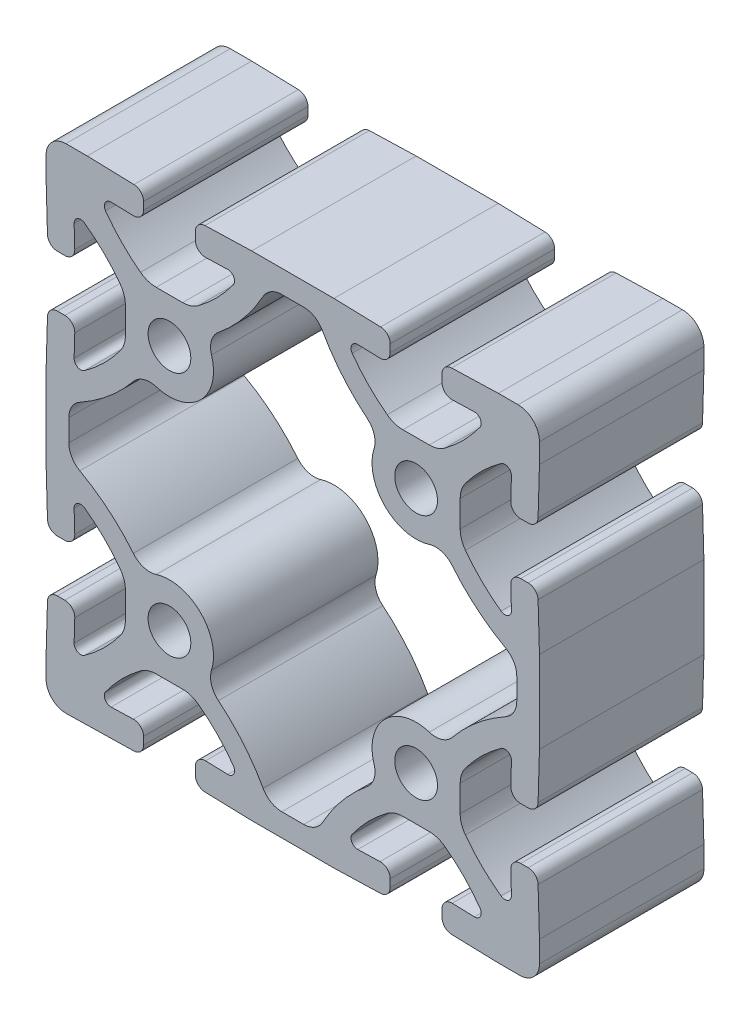
from build123d import *

# Parameters (mm, degrees)
SKETCH1_R      = 3.302
EXTRUDE1_DEPTH = 25.4


with BuildPart() as part:
    # Sketch1 → Extrude1 (new body)
    with BuildSketch(Plane.XY):
        with BuildLine():
            Line((69.825208207, 103.819239098), (69.825208207, 107.121239098))
            Line((69.825208207, 107.121239098), (70.036010467, 114.341216494))
            ThreePointArc((70.036010467, 114.341216494), (70.497572138, 115.389981878), (71.5593613, 115.820739098))
            Line((71.5593613, 115.820739098), (72.728259206, 115.820739098))
            ThreePointArc((72.728259206, 115.820739098), (73.821501987, 115.358528259), (74.25161004, 114.252261701))
            Line((74.25161004, 114.252261701), (74.151058928, 110.808386114))
            ThreePointArc((74.151058928, 110.808386114), (74.688858525, 109.882077337), (75.757661575, 109.952336835))
            ThreePointArc((75.757661575, 109.952336835), (78.720086302, 112.43897136), (81.263390359, 115.352888998))
            ThreePointArc((81.263390359, 115.352888998), (81.861612714, 116.501676437), (82.068008207, 117.780341157))
            Line((82.068008207, 117.780341157), (82.068008207, 121.862137038))
            ThreePointArc((82.068008207, 121.862137038), (81.861612714, 123.140801758), (81.263390359, 124.289589198))
            ThreePointArc((81.263390359, 124.289589198), (78.720086302, 127.203506835), (75.757661575, 129.69014136))
            ThreePointArc((75.757661575, 129.69014136), (74.688858525, 129.760400858), (74.151058928, 128.834092081))
            Line((74.151058928, 128.834092081), (74.25161004, 125.390216494))
            ThreePointArc((74.25161004, 125.390216494), (73.821501987, 124.283949936), (72.728259206, 123.821739098))
            Line((72.728259206, 123.821739098), (71.5593613, 123.821739098))
            ThreePointArc((71.5593613, 123.821739098), (70.497572138, 124.252496317), (70.036010467, 125.301261701))
            Line((70.036010467, 125.301261701), (69.825208207, 132.521239098))
            Line((69.825208207, 132.521239098), (69.825208207, 145.221239098))
            Line((69.825208207, 145.221239098), (70.036010467, 152.441216494))
            ThreePointArc((70.036010467, 152.441216494), (70.497572138, 153.489981878), (71.5593613, 153.920739098))
            Line((71.5593613, 153.920739098), (72.728259206, 153.920739098))
            ThreePointArc((72.728259206, 153.920739098), (73.821501987, 153.458528259), (74.25161004, 152.352261701))
            Line((74.25161004, 152.352261701), (74.151058928, 148.908386114))
            ThreePointArc((74.151058928, 148.908386114), (74.688858525, 147.982077337), (75.757661575, 148.052336835))
            ThreePointArc((75.757661575, 148.052336835), (78.720086302, 150.53897136), (81.263390359, 153.452888998))
            ThreePointArc((81.263390359, 153.452888998), (81.861612714, 154.601676437), (82.068008207, 155.880341157))
            Line((82.068008207, 155.880341157), (82.068008207, 157.921239098))
            Line((82.068008207, 157.921239098), (82.068008207, 159.962137038))
            ThreePointArc((82.068008207, 159.962137038), (81.861612714, 161.240801758), (81.263390359, 162.389589198))
            ThreePointArc((81.263390359, 162.389589198), (78.720086302, 165.303506835), (75.757661575, 167.79014136))
            ThreePointArc((75.757661575, 167.79014136), (74.688858525, 167.860400858), (74.151058928, 166.934092081))
            Line((74.151058928, 166.934092081), (74.25161004, 163.490216494))
            ThreePointArc((74.25161004, 163.490216494), (73.821501987, 162.383949936), (72.728259206, 161.921739098))
            Line((72.728259206, 161.921739098), (71.5593613, 161.921739098))
            ThreePointArc((71.5593613, 161.921739098), (70.497572138, 162.352496317), (70.036010467, 163.401261701))
            Line((70.036010467, 163.401261701), (69.825208207, 170.621239098))
            Line((69.825208207, 170.621239098), (69.825208207, 173.923239098))
            ThreePointArc((69.825208207, 173.923239098), (70.717946738, 176.078500567), (72.873208207, 176.971239098))
            Line((72.873208207, 176.971239098), (76.175208207, 176.971239098))
            Line((76.175208207, 176.971239098), (83.395185603, 176.760436838))
            ThreePointArc((83.395185603, 176.760436838), (84.443950987, 176.298875166), (84.874708207, 175.237086005))
            Line((84.874708207, 175.237086005), (84.874708207, 174.068188098))
            ThreePointArc((84.874708207, 174.068188098), (84.412497369, 172.974945318), (83.30623081, 172.544837265))
            Line((83.30623081, 172.544837265), (79.862355223, 172.645388377))
            ThreePointArc((79.862355223, 172.645388377), (78.936046446, 172.10758878), (79.006305945, 171.03878573))
            ThreePointArc((79.006305945, 171.03878573), (81.49294047, 168.076361003), (84.406858107, 165.533056946))
            ThreePointArc((84.406858107, 165.533056946), (85.555645546, 164.93483459), (86.834310267, 164.728439098))
            Line((86.834310267, 164.728439098), (90.916106147, 164.728439098))
            ThreePointArc((90.916106147, 164.728439098), (92.194770868, 164.93483459), (93.343558307, 165.533056946))
            ThreePointArc((93.343558307, 165.533056946), (96.257475944, 168.076361003), (98.744110469, 171.03878573))
            ThreePointArc((98.744110469, 171.03878573), (98.814369967, 172.10758878), (97.888061191, 172.645388377))
            Line((97.888061191, 172.645388377), (94.444185603, 172.544837265))
            ThreePointArc((94.444185603, 172.544837265), (93.337919045, 172.974945318), (92.875708207, 174.068188098))
            Line((92.875708207, 174.068188098), (92.875708207, 175.237086005))
            ThreePointArc((92.875708207, 175.237086005), (93.306465427, 176.298875166), (94.35523081, 176.760436838))
            Line((94.35523081, 176.760436838), (101.575208207, 176.971239098))
            Line((101.575208207, 176.971239098), (107.925208207, 176.971239098))
            Line((107.925208207, 176.971239098), (114.275208207, 176.971239098))
            Line((114.275208207, 176.971239098), (121.495185603, 176.760436838))
            ThreePointArc((121.495185603, 176.760436838), (122.543950987, 176.298875166), (122.974708207, 175.237086005))
            Line((122.974708207, 175.237086005), (122.974708207, 174.068188098))
            ThreePointArc((122.974708207, 174.068188098), (122.512497369, 172.974945318), (121.40623081, 172.544837265))
            Line((121.40623081, 172.544837265), (117.962355223, 172.645388377))
            ThreePointArc((117.962355223, 172.645388377), (117.036046446, 172.10758878), (117.106305945, 171.03878573))
            ThreePointArc((117.106305945, 171.03878573), (119.59294047, 168.076361003), (122.506858107, 165.533056946))
            ThreePointArc((122.506858107, 165.533056946), (123.655645546, 164.93483459), (124.934310267, 164.728439098))
            Line((124.934310267, 164.728439098), (126.975208207, 164.728439098))
            Line((126.975208207, 164.728439098), (129.016106147, 164.728439098))
            ThreePointArc((129.016106147, 164.728439098), (130.294770868, 164.93483459), (131.443558307, 165.533056946))
            ThreePointArc((131.443558307, 165.533056946), (134.357475944, 168.076361003), (136.844110469, 171.03878573))
            ThreePointArc((136.844110469, 171.03878573), (136.914369967, 172.10758878), (135.988061191, 172.645388377))
            Line((135.988061191, 172.645388377), (132.544185603, 172.544837265))
            ThreePointArc((132.544185603, 172.544837265), (131.437919045, 172.974945318), (130.975708207, 174.068188098))
            Line((130.975708207, 174.068188098), (130.975708207, 175.237086005))
            ThreePointArc((130.975708207, 175.237086005), (131.406465427, 176.298875166), (132.45523081, 176.760436838))
            Line((132.45523081, 176.760436838), (139.675208207, 176.971239098))
            Line((139.675208207, 176.971239098), (142.723208207, 176.971239098))
            ThreePointArc((142.723208207, 176.971239098), (145.058074798, 176.004105689), (146.025208207, 173.669239098))
            Line((146.025208207, 173.669239098), (146.025208207, 170.621239098))
            Line((146.025208207, 170.621239098), (145.814405947, 163.401261701))
            ThreePointArc((145.814405947, 163.401261701), (145.352844275, 162.352496317), (144.291055114, 161.921739098))
            Line((144.291055114, 161.921739098), (143.122157207, 161.921739098))
            ThreePointArc((143.122157207, 161.921739098), (142.028914427, 162.383949936), (141.598806374, 163.490216494))
            Line((141.598806374, 163.490216494), (141.699357486, 166.934092081))
            ThreePointArc((141.699357486, 166.934092081), (141.161557889, 167.860400858), (140.092754839, 167.79014136))
            ThreePointArc((140.092754839, 167.79014136), (137.130330112, 165.303506835), (134.587026055, 162.389589198))
            ThreePointArc((134.587026055, 162.389589198), (133.9888037, 161.240801758), (133.782408207, 159.962137038))
            Line((133.782408207, 159.962137038), (133.782408207, 157.921239098))
            Line((133.782408207, 157.921239098), (133.782408207, 155.880341157))
            ThreePointArc((133.782408207, 155.880341157), (133.9888037, 154.601676437), (134.587026055, 153.452888998))
            ThreePointArc((134.587026055, 153.452888998), (137.130330112, 150.53897136), (140.092754839, 148.052336835))
            ThreePointArc((140.092754839, 148.052336835), (141.161557889, 147.982077337), (141.699357486, 148.908386114))
            Line((141.699357486, 148.908386114), (141.598806374, 152.352261701))
            ThreePointArc((141.598806374, 152.352261701), (142.028914427, 153.458528259), (143.122157207, 153.920739098))
            Line((143.122157207, 153.920739098), (144.291055114, 153.920739098))
            ThreePointArc((144.291055114, 153.920739098), (145.352844275, 153.489981878), (145.814405947, 152.441216494))
            Line((145.814405947, 152.441216494), (146.025208207, 145.221239098))
            Line((146.025208207, 145.221239098), (146.025208207, 138.871239098))
            Line((146.025208207, 138.871239098), (146.025208207, 132.521239098))
            Line((146.025208207, 132.521239098), (145.814405947, 125.301261701))
            ThreePointArc((145.814405947, 125.301261701), (145.352844275, 124.252496317), (144.291055114, 123.821739098))
            Line((144.291055114, 123.821739098), (143.122157207, 123.821739098))
            ThreePointArc((143.122157207, 123.821739098), (142.028914427, 124.283949936), (141.598806374, 125.390216494))
            Line((141.598806374, 125.390216494), (141.699357486, 128.834092081))
            ThreePointArc((141.699357486, 128.834092081), (141.161557889, 129.760400858), (140.092754839, 129.69014136))
            ThreePointArc((140.092754839, 129.69014136), (137.130330112, 127.203506835), (134.587026055, 124.289589198))
            ThreePointArc((134.587026055, 124.289589198), (133.9888037, 123.140801758), (133.782408207, 121.862137038))
            Line((133.782408207, 121.862137038), (133.782408207, 117.780341157))
            ThreePointArc((133.782408207, 117.780341157), (133.9888037, 116.501676437), (134.587026055, 115.352888998))
            ThreePointArc((134.587026055, 115.352888998), (137.130330112, 112.43897136), (140.092754839, 109.952336835))
            ThreePointArc((140.092754839, 109.952336835), (141.161557889, 109.882077337), (141.699357486, 110.808386114))
            Line((141.699357486, 110.808386114), (141.598806374, 114.252261701))
            ThreePointArc((141.598806374, 114.252261701), (142.028914427, 115.358528259), (143.122157207, 115.820739098))
            Line((143.122157207, 115.820739098), (144.291055114, 115.820739098))
            ThreePointArc((144.291055114, 115.820739098), (145.352844275, 115.389981878), (145.814405947, 114.341216494))
            Line((145.814405947, 114.341216494), (146.025208207, 107.121239098))
            Line((146.025208207, 107.121239098), (146.025208207, 103.819239098))
            ThreePointArc((146.025208207, 103.819239098), (145.132469676, 101.663977628), (142.977208207, 100.771239098))
            Line((142.977208207, 100.771239098), (139.675208207, 100.771239098))
            Line((139.675208207, 100.771239098), (132.45523081, 100.982041357))
            ThreePointArc((132.45523081, 100.982041357), (131.406465427, 101.443603029), (130.975708207, 102.505392191))
            Line((130.975708207, 102.505392191), (130.975708207, 103.674290097))
            ThreePointArc((130.975708207, 103.674290097), (131.437919045, 104.767532877), (132.544185603, 105.19764093))
            Line((132.544185603, 105.19764093), (135.988061191, 105.097089818))
            ThreePointArc((135.988061191, 105.097089818), (136.914369967, 105.634889416), (136.844110469, 106.703692465))
            ThreePointArc((136.844110469, 106.703692465), (134.357475944, 109.666117192), (131.443558307, 112.209421249))
            ThreePointArc((131.443558307, 112.209421249), (130.294770868, 112.807643605), (129.016106147, 113.014039098))
            Line((129.016106147, 113.014039098), (126.975208207, 113.014039098))
            Line((126.975208207, 113.014039098), (124.934310267, 113.014039098))
            ThreePointArc((124.934310267, 113.014039098), (123.655645546, 112.807643605), (122.506858107, 112.209421249))
            ThreePointArc((122.506858107, 112.209421249), (119.59294047, 109.666117192), (117.106305945, 106.703692465))
            ThreePointArc((117.106305945, 106.703692465), (117.036046446, 105.634889416), (117.962355223, 105.097089818))
            Line((117.962355223, 105.097089818), (121.40623081, 105.19764093))
            ThreePointArc((121.40623081, 105.19764093), (122.512497369, 104.767532877), (122.974708207, 103.674290097))
            Line((122.974708207, 103.674290097), (122.974708207, 102.505392191))
            ThreePointArc((122.974708207, 102.505392191), (122.543950987, 101.443603029), (121.495185603, 100.982041357))
            Line((121.495185603, 100.982041357), (114.275208207, 100.771239098))
            Line((114.275208207, 100.771239098), (101.575208207, 100.771239098))
            Line((101.575208207, 100.771239098), (94.35523081, 100.982041357))
            ThreePointArc((94.35523081, 100.982041357), (93.306465427, 101.443603029), (92.875708207, 102.505392191))
            Line((92.875708207, 102.505392191), (92.875708207, 103.674290097))
            ThreePointArc((92.875708207, 103.674290097), (93.337919045, 104.767532877), (94.444185603, 105.19764093))
            Line((94.444185603, 105.19764093), (97.888061191, 105.097089818))
            ThreePointArc((97.888061191, 105.097089818), (98.814369967, 105.634889416), (98.744110469, 106.703692465))
            ThreePointArc((98.744110469, 106.703692465), (96.257475944, 109.666117192), (93.343558307, 112.209421249))
            ThreePointArc((93.343558307, 112.209421249), (92.194770868, 112.807643605), (90.916106147, 113.014039098))
            Line((90.916106147, 113.014039098), (86.834310267, 113.014039098))
            ThreePointArc((86.834310267, 113.014039098), (85.555645546, 112.807643605), (84.406858107, 112.209421249))
            ThreePointArc((84.406858107, 112.209421249), (81.492943562, 109.666147953), (79.006304665, 106.703756346))
            ThreePointArc((79.006304665, 106.703756346), (78.936045167, 105.634953296), (79.862353943, 105.097153699))
            Line((79.862353943, 105.097153699), (83.30622953, 105.197704811))
            ThreePointArc((83.30622953, 105.197704811), (84.412496089, 104.767596758), (84.874706927, 103.674353978))
            Line((84.874706927, 103.674353978), (84.874706927, 102.505456071))
            ThreePointArc((84.874706927, 102.505456071), (84.439076866, 101.438672646), (83.381233336, 100.981761831))
            Line((83.381233336, 100.981761831), (72.873208207, 100.771239098))
            ThreePointArc((72.873208207, 100.771239098), (70.717946738, 101.663977628), (69.825208207, 103.819239098))
        make_face()
        with Locations((88.875208207, 119.821239098)):
            Circle(SKETCH1_R, mode=Mode.SUBTRACT)
        with Locations((88.875208207, 157.921239098)):
            Circle(SKETCH1_R, mode=Mode.SUBTRACT)
        with Locations((126.975208207, 119.821239098)):
            Circle(SKETCH1_R, mode=Mode.SUBTRACT)
        with Locations((126.975208207, 157.921239098)):
            Circle(SKETCH1_R, mode=Mode.SUBTRACT)
        with BuildLine():
            Line((106.230060734, 173.466039098), (109.62035568, 173.466039098))
            ThreePointArc((109.62035568, 173.466039098), (111.296406701, 173.009044717), (112.508529256, 171.76455695))
            ThreePointArc((112.508529256, 171.76455695), (115.568085048, 167.302877466), (119.415653445, 163.499762575))
            ThreePointArc((119.415653445, 163.499762575), (120.490540898, 161.890377761), (120.478943654, 159.955082431))
            ThreePointArc((120.478943654, 159.955082431), (122.161790926, 153.107821817), (129.00905154, 151.424974545))
            ThreePointArc((129.00905154, 151.424974545), (130.944346871, 151.436571788), (132.553731684, 150.361684336))
            ThreePointArc((132.553731684, 150.361684336), (136.356846576, 146.514115938), (140.818526059, 143.454560147))
            ThreePointArc((140.818526059, 143.454560147), (142.063013826, 142.242437592), (142.520008207, 140.566386571))
            Line((142.520008207, 140.566386571), (142.520008207, 137.176091624))
            ThreePointArc((142.520008207, 137.176091624), (142.063013826, 135.500040603), (140.818526059, 134.287918048))
            ThreePointArc((140.818526059, 134.287918048), (136.356846576, 131.228362257), (132.553731684, 127.380793859))
            ThreePointArc((132.553731684, 127.380793859), (130.944346871, 126.305906407), (129.00905154, 126.31750365))
            ThreePointArc((129.00905154, 126.31750365), (122.161790926, 124.634656378), (120.478943654, 117.787395764))
            ThreePointArc((120.478943654, 117.787395764), (120.490540898, 115.852100434), (119.415653445, 114.24271562))
            ThreePointArc((119.415653445, 114.24271562), (115.568085048, 110.439600729), (112.508529256, 105.977921246))
            ThreePointArc((112.508529256, 105.977921246), (111.296406701, 104.733433478), (109.62035568, 104.276439098))
            Line((109.62035568, 104.276439098), (106.230060734, 104.276439098))
            ThreePointArc((106.230060734, 104.276439098), (104.554009712, 104.733433478), (103.341887158, 105.977921246))
            ThreePointArc((103.341887158, 105.977921246), (100.282331366, 110.439600729), (96.434762969, 114.24271562))
            ThreePointArc((96.434762969, 114.24271562), (95.359875516, 115.852100434), (95.371472759, 117.787395764))
            ThreePointArc((95.371472759, 117.787395764), (93.688625488, 124.634656378), (86.841364874, 126.31750365))
            ThreePointArc((86.841364874, 126.31750365), (84.906069543, 126.305906407), (83.29668473, 127.380793859))
            ThreePointArc((83.29668473, 127.380793859), (79.493569838, 131.228362257), (75.031890355, 134.287918048))
            ThreePointArc((75.031890355, 134.287918048), (73.787402588, 135.500040603), (73.330408207, 137.176091624))
            Line((73.330408207, 137.176091624), (73.330408207, 140.566386571))
            ThreePointArc((73.330408207, 140.566386571), (73.787402588, 142.242437592), (75.031890355, 143.454560147))
            ThreePointArc((75.031890355, 143.454560147), (79.493569838, 146.514115938), (83.29668473, 150.361684336))
            ThreePointArc((83.29668473, 150.361684336), (84.906069543, 151.436571788), (86.841364874, 151.424974545))
            ThreePointArc((86.841364874, 151.424974545), (93.688625488, 153.107821817), (95.371472759, 159.955082431))
            ThreePointArc((95.371472759, 159.955082431), (95.359875516, 161.890377761), (96.434762969, 163.499762575))
            ThreePointArc((96.434762969, 163.499762575), (100.282331366, 167.302877466), (103.341887158, 171.76455695))
            ThreePointArc((103.341887158, 171.76455695), (104.554009712, 173.009044717), (106.230060734, 173.466039098))
        make_face(mode=Mode.SUBTRACT)
    extrude(amount=EXTRUDE1_DEPTH)


solid = part.part
